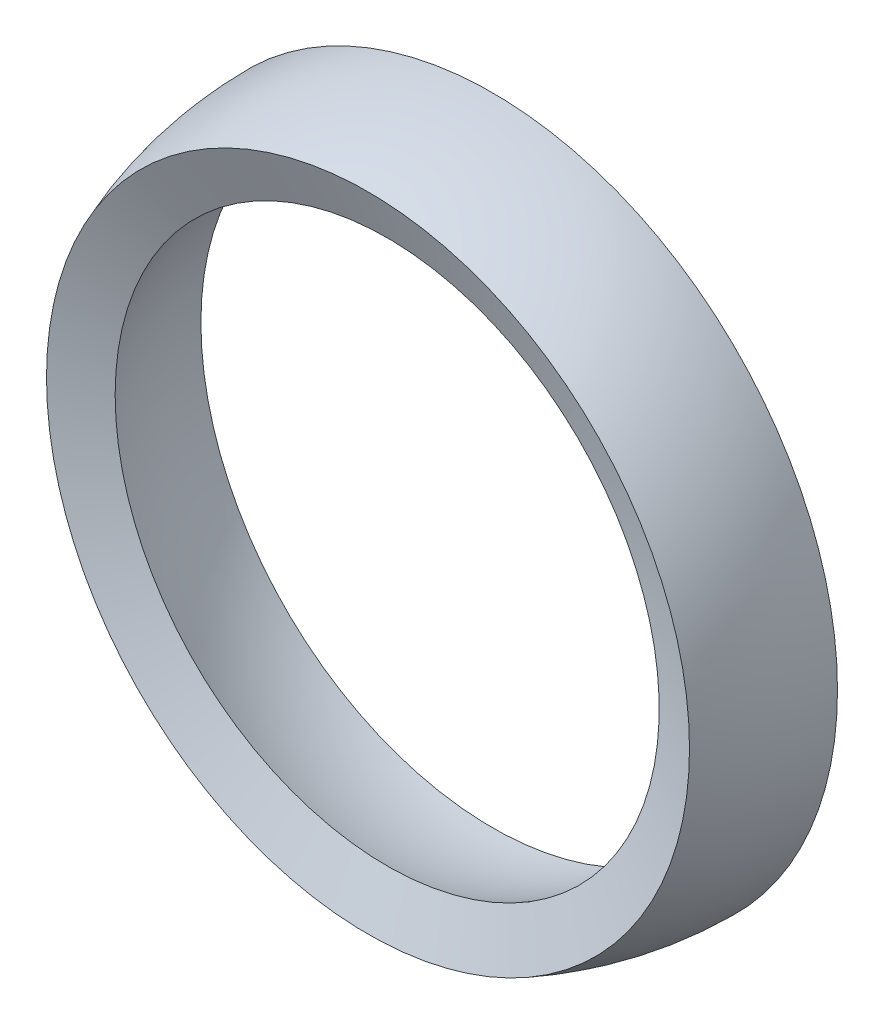
from build123d import *


with BuildPart() as part:
    # Sketch6 → Revolve3 (revolve)
    with BuildSketch(Plane(origin=(0, 0, 0), x_dir=(1, 0, 0), z_dir=(0, 1, 0))):
        with BuildLine():
            Line((-22, 0), (-26, 0))
            ThreePointArc((-26, 0), (-25.556555776, -4.781470158), (-24.241349471, -9.399839137))
            Line((-24.241349471, -9.399839137), (-20.511911091, -7.953710039))
            ThreePointArc((-20.511911091, -7.953710039), (-21.624777964, -4.045859364), (-22, 0))
        make_face()
    revolve(axis=Axis((0, 0, 0), (0, 0, 1)))


solid = part.part
